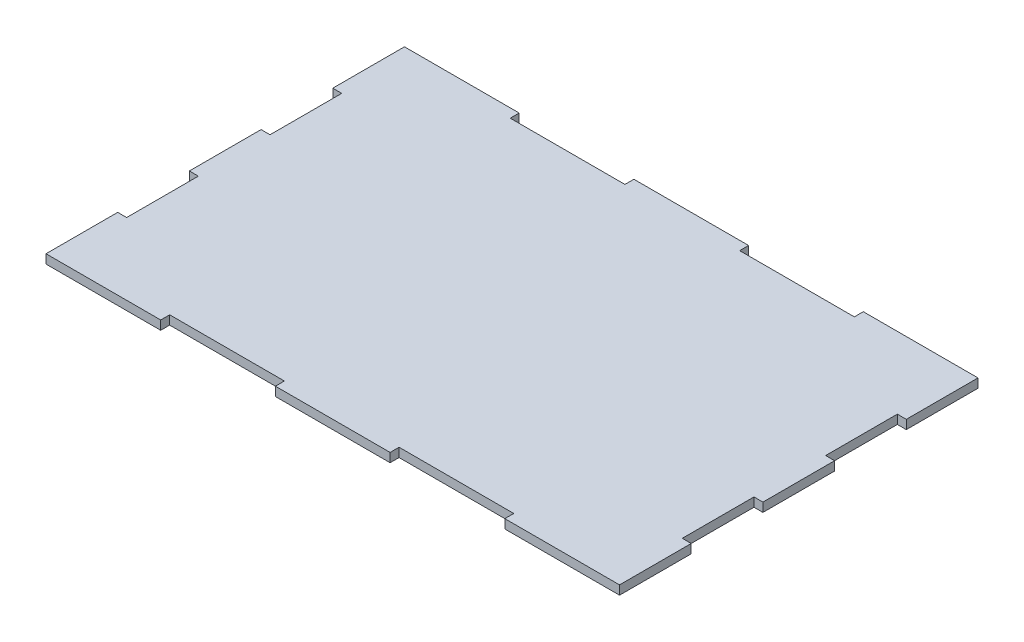
from build123d import *

# Parameters (mm, degrees)
SKETCH1_W           = 203.2
SKETCH1_H           = 127
BOSS_EXTRUDE1_DEPTH = 3.175
SKETCH3_W           = 40.64
SKETCH3_H           = 3.175
CUT_EXTRUDE1_DEPTH  = 3.175
LPATTERN1_COUNT     = 2
LPATTERN1_PITCH     = 81.28
SKETCH5_W           = 40.64
SKETCH5_H           = 3.175
CUT_EXTRUDE2_DEPTH  = 3.175
LPATTERN2_COUNT     = 2
LPATTERN2_PITCH     = 81.28
SKETCH6_W           = 3.175
SKETCH6_H           = 25.4
CUT_EXTRUDE3_DEPTH  = 3.175
LPATTERN3_COUNT     = 2
LPATTERN3_PITCH     = 50.8
SKETCH7_W           = 3.175
SKETCH7_H           = 25.4
CUT_EXTRUDE4_DEPTH  = 3.175
LPATTERN4_COUNT     = 2
LPATTERN4_PITCH     = 50.8


with BuildPart() as part:
    # Sketch1 → Boss-Extrude1 (new body)
    with BuildSketch(Plane(origin=(0, 0, 0), x_dir=(1, 0, 0), z_dir=(0, 1, 0))):
        Rectangle(SKETCH1_W, SKETCH1_H)
    extrude(amount=BOSS_EXTRUDE1_DEPTH)

    # Sketch3 → Cut-Extrude1 (cut)
    with BuildSketch(Plane(origin=(0, 3.175, 0), x_dir=(1, 0, 0), z_dir=(0, 1, 0))):
        with Locations((-40.64, -61.9125)):
            Rectangle(SKETCH3_W, SKETCH3_H)
    cut_extrude1 = extrude(amount=-CUT_EXTRUDE1_DEPTH, mode=Mode.SUBTRACT)

    # LPattern1: Cut-Extrude1 ×2
    with Locations(*[(i * LPATTERN1_PITCH, 0, 0) for i in range(1, LPATTERN1_COUNT)]):
        add(cut_extrude1, mode=Mode.SUBTRACT)

    # Sketch5 → Cut-Extrude2 (cut)
    with BuildSketch(Plane(origin=(0, 3.175, 0), x_dir=(1, 0, 0), z_dir=(0, 1, 0))):
        with Locations((-40.64, 61.9125)):
            Rectangle(SKETCH5_W, SKETCH5_H)
    cut_extrude2 = extrude(amount=-CUT_EXTRUDE2_DEPTH, mode=Mode.SUBTRACT)

    # LPattern2: Cut-Extrude2 ×2
    with Locations(*[(i * LPATTERN2_PITCH, 0, 0) for i in range(1, LPATTERN2_COUNT)]):
        add(cut_extrude2, mode=Mode.SUBTRACT)

    # Sketch6 → Cut-Extrude3 (cut)
    with BuildSketch(Plane(origin=(0, 3.175, 0), x_dir=(1, 0, 0), z_dir=(0, 1, 0))):
        with Locations((-100.0125, -25.4)):
            Rectangle(SKETCH6_W, SKETCH6_H)
    cut_extrude3 = extrude(amount=-CUT_EXTRUDE3_DEPTH, mode=Mode.SUBTRACT)

    # LPattern3: Cut-Extrude3 ×2
    with Locations(*[(0, 0, -i * LPATTERN3_PITCH) for i in range(1, LPATTERN3_COUNT)]):
        add(cut_extrude3, mode=Mode.SUBTRACT)

    # Sketch7 → Cut-Extrude4 (cut)
    with BuildSketch(Plane(origin=(0, 3.175, 0), x_dir=(1, 0, 0), z_dir=(0, 1, 0))):
        with Locations((100.0125, -25.4)):
            Rectangle(SKETCH7_W, SKETCH7_H)
    cut_extrude4 = extrude(amount=-CUT_EXTRUDE4_DEPTH, mode=Mode.SUBTRACT)

    # LPattern4: Cut-Extrude4 ×2
    with Locations(*[(0, 0, -i * LPATTERN4_PITCH) for i in range(1, LPATTERN4_COUNT)]):
        add(cut_extrude4, mode=Mode.SUBTRACT)


solid = part.part
